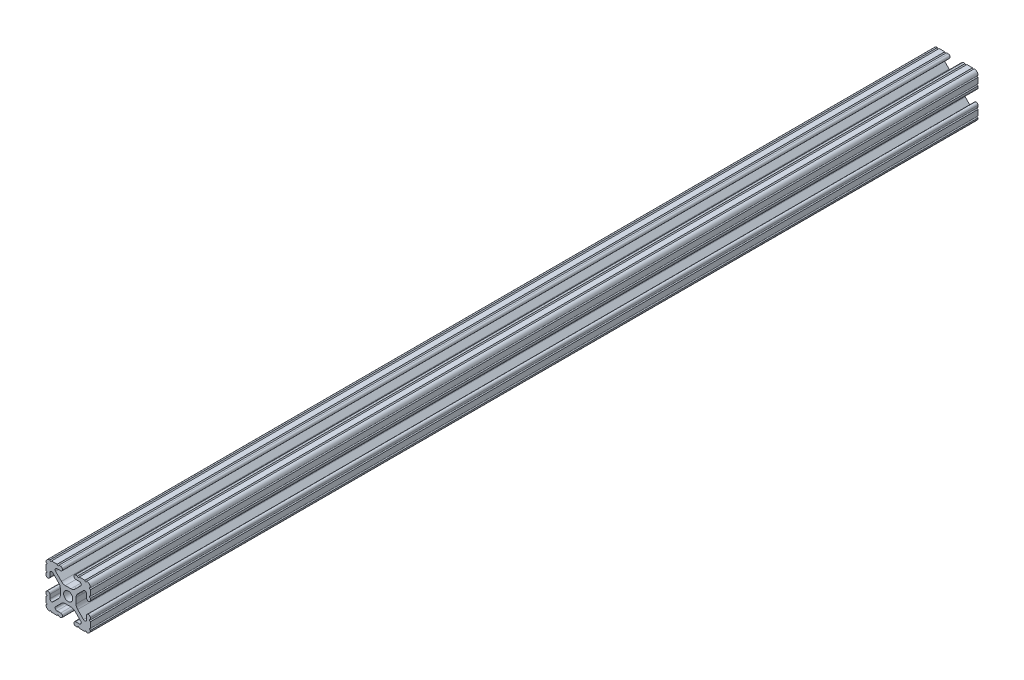
from build123d import *

# Parameters (mm, degrees)
SKETCH1_R           = 2.6035
BOSS_EXTRUDE1_DEPTH = 508


with BuildPart() as part:
    # Sketch1 → Boss-Extrude1 (new body)
    with BuildSketch(Plane.XY):
        with BuildLine():
            Line((-12.7, -6.3330836), (-12.7, -9.5504))
            ThreePointArc((-12.7, -9.5504), (-12.192000006, -10.058323491), (-12.699846982, -10.566399977))
            ThreePointArc((-12.699846982, -10.566399977), (-12.082522516, -12.082522516), (-10.566399977, -12.699846982))
            ThreePointArc((-10.566399977, -12.699846982), (-10.058323491, -12.192000006), (-9.5504, -12.7))
            Line((-9.5504, -12.7), (-6.3330836, -12.7))
            ThreePointArc((-6.3330836, -12.7), (-5.8250836, -12.192), (-5.3170836, -12.7))
            Line((-5.3170836, -12.7), (-4.343399971, -12.7))
            ThreePointArc((-4.343399971, -12.7), (-3.238499971, -11.5951), (-4.343399971, -10.4902))
            Line((-4.343399971, -10.4902), (-6.474794456, -10.4902))
            ThreePointArc((-6.474794456, -10.4902), (-7.413456061, -9.863006367), (-7.193214945, -8.75577951))
            Line((-7.193214945, -8.75577951), (-3.863171405, -5.42573597))
            ThreePointArc((-3.863171405, -5.42573597), (-2.833127272, -4.737482484), (-1.618107374, -4.4958))
            Line((-1.618107374, -4.4958), (1.618107374, -4.4958))
            ThreePointArc((1.618107374, -4.4958), (2.833127272, -4.737482484), (3.863171405, -5.42573597))
            Line((3.863171405, -5.42573597), (7.193214945, -8.75577951))
            ThreePointArc((7.193214945, -8.75577951), (7.413456061, -9.863006367), (6.474794456, -10.4902))
            Line((6.474794456, -10.4902), (4.3434, -10.4902))
            ThreePointArc((4.3434, -10.4902), (3.2385, -11.5951), (4.3434, -12.7))
            Line((4.3434, -12.7), (5.3170836, -12.7))
            ThreePointArc((5.3170836, -12.7), (5.8250836, -12.192), (6.3330836, -12.7))
            Line((6.3330836, -12.7), (9.5504, -12.7))
            ThreePointArc((9.5504, -12.7), (10.058323491, -12.192000006), (10.566399977, -12.699846982))
            ThreePointArc((10.566399977, -12.699846982), (12.082522516, -12.082522516), (12.699846982, -10.566399977))
            ThreePointArc((12.699846982, -10.566399977), (12.192000006, -10.058323491), (12.7, -9.5504))
            Line((12.7, -9.5504), (12.7, -6.3330836))
            ThreePointArc((12.7, -6.3330836), (12.192, -5.8250836), (12.7, -5.3170836))
            Line((12.7, -5.3170836), (12.7, -4.343399971))
            ThreePointArc((12.7, -4.343399971), (11.5951, -3.238499971), (10.4902, -4.343399971))
            Line((10.4902, -4.343399971), (10.4902, -6.474794456))
            ThreePointArc((10.4902, -6.474794456), (9.863006367, -7.413456061), (8.75577951, -7.193214945))
            Line((8.75577951, -7.193214945), (5.42573597, -3.863171405))
            ThreePointArc((5.42573597, -3.863171405), (4.737482484, -2.833127272), (4.4958, -1.618107374))
            Line((4.4958, -1.618107374), (4.4958, 1.618107374))
            ThreePointArc((4.4958, 1.618107374), (4.737482484, 2.833127272), (5.42573597, 3.863171405))
            Line((5.42573597, 3.863171405), (8.75577951, 7.193214945))
            ThreePointArc((8.75577951, 7.193214945), (9.863006367, 7.413456061), (10.4902, 6.474794456))
            Line((10.4902, 6.474794456), (10.4902, 4.3434))
            ThreePointArc((10.4902, 4.3434), (11.5951, 3.2385), (12.7, 4.3434))
            Line((12.7, 4.3434), (12.7, 5.3170836))
            ThreePointArc((12.7, 5.3170836), (12.192, 5.8250836), (12.7, 6.3330836))
            Line((12.7, 6.3330836), (12.7, 9.5504))
            ThreePointArc((12.7, 9.5504), (12.192000006, 10.058323491), (12.699846982, 10.566399977))
            ThreePointArc((12.699846982, 10.566399977), (12.082522516, 12.082522516), (10.566399977, 12.699846982))
            ThreePointArc((10.566399977, 12.699846982), (10.058323491, 12.192000006), (9.5504, 12.7))
            Line((9.5504, 12.7), (6.3330836, 12.7))
            ThreePointArc((6.3330836, 12.7), (5.8250836, 12.192), (5.3170836, 12.7))
            Line((5.3170836, 12.7), (4.343399971, 12.7))
            ThreePointArc((4.343399971, 12.7), (3.238499971, 11.5951), (4.343399971, 10.4902))
            Line((4.343399971, 10.4902), (6.474794456, 10.4902))
            ThreePointArc((6.474794456, 10.4902), (7.413456061, 9.863006367), (7.193214945, 8.75577951))
            Line((7.193214945, 8.75577951), (3.863171405, 5.42573597))
            ThreePointArc((3.863171405, 5.42573597), (2.833127272, 4.737482484), (1.618107374, 4.4958))
            Line((1.618107374, 4.4958), (-1.618107374, 4.4958))
            ThreePointArc((-1.618107374, 4.4958), (-2.833127272, 4.737482484), (-3.863171405, 5.42573597))
            Line((-3.863171405, 5.42573597), (-7.193214945, 8.75577951))
            ThreePointArc((-7.193214945, 8.75577951), (-7.413456061, 9.863006367), (-6.474794456, 10.4902))
            Line((-6.474794456, 10.4902), (-4.3434, 10.4902))
            ThreePointArc((-4.3434, 10.4902), (-3.2385, 11.5951), (-4.3434, 12.7))
            Line((-4.3434, 12.7), (-5.3170836, 12.7))
            ThreePointArc((-5.3170836, 12.7), (-5.8250836, 12.192), (-6.3330836, 12.7))
            Line((-6.3330836, 12.7), (-9.5504, 12.7))
            ThreePointArc((-9.5504, 12.7), (-10.058323491, 12.192000006), (-10.566399977, 12.699846982))
            ThreePointArc((-10.566399977, 12.699846982), (-12.082522516, 12.082522516), (-12.699846982, 10.566399977))
            ThreePointArc((-12.699846982, 10.566399977), (-12.192000006, 10.058323491), (-12.7, 9.5504))
            Line((-12.7, 9.5504), (-12.7, 6.3330836))
            ThreePointArc((-12.7, 6.3330836), (-12.192, 5.8250836), (-12.7, 5.3170836))
            Line((-12.7, 5.3170836), (-12.7, 4.343399971))
            ThreePointArc((-12.7, 4.343399971), (-11.5951, 3.238499971), (-10.4902, 4.343399971))
            Line((-10.4902, 4.343399971), (-10.4902, 6.474794456))
            ThreePointArc((-10.4902, 6.474794456), (-9.863006367, 7.413456061), (-8.75577951, 7.193214945))
            Line((-8.75577951, 7.193214945), (-5.42573597, 3.863171405))
            ThreePointArc((-5.42573597, 3.863171405), (-4.737482484, 2.833127272), (-4.4958, 1.618107374))
            Line((-4.4958, 1.618107374), (-4.4958, -1.618107374))
            ThreePointArc((-4.4958, -1.618107374), (-4.737482484, -2.833127272), (-5.42573597, -3.863171405))
            Line((-5.42573597, -3.863171405), (-8.75577951, -7.193214945))
            ThreePointArc((-8.75577951, -7.193214945), (-9.863006367, -7.413456061), (-10.4902, -6.474794456))
            Line((-10.4902, -6.474794456), (-10.4902, -4.3434))
            ThreePointArc((-10.4902, -4.3434), (-11.5951, -3.2385), (-12.7, -4.3434))
            Line((-12.7, -4.3434), (-12.7, -5.3170836))
            ThreePointArc((-12.7, -5.3170836), (-12.192, -5.8250836), (-12.7, -6.3330836))
        make_face()
        Circle(SKETCH1_R, mode=Mode.SUBTRACT)
    extrude(amount=-BOSS_EXTRUDE1_DEPTH)


solid = part.part
